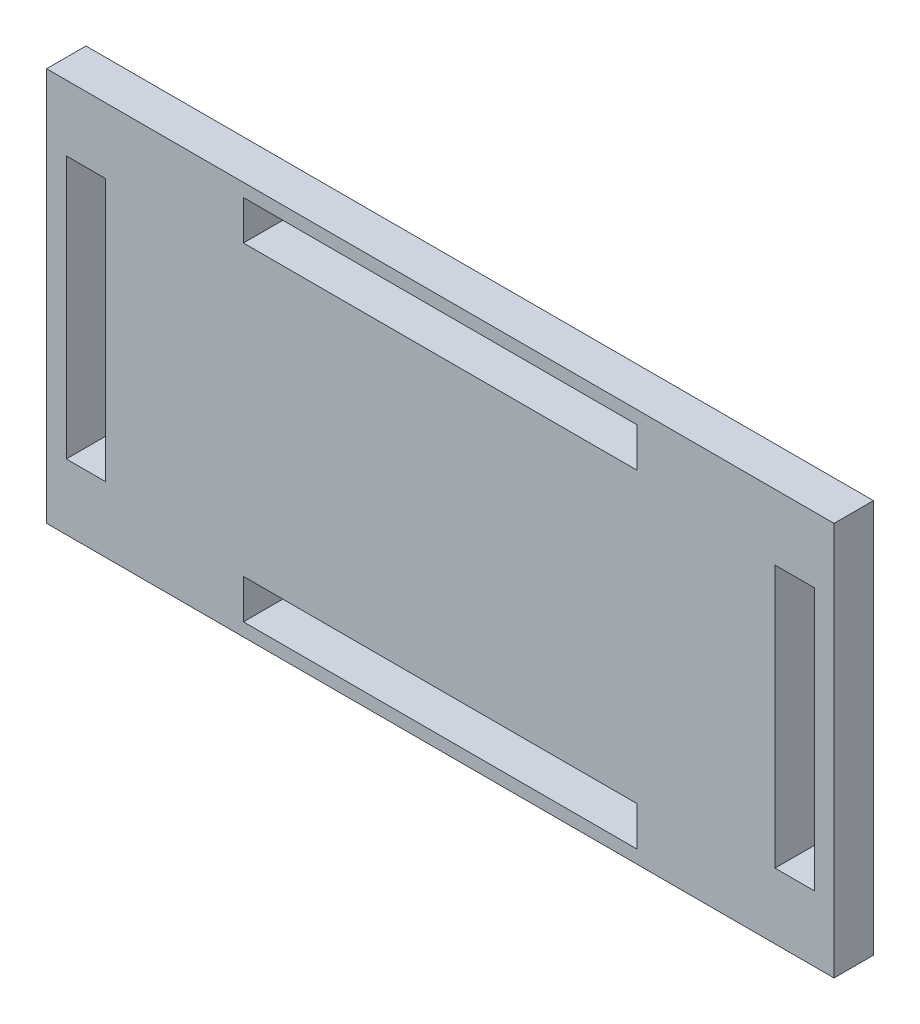
from build123d import *

# Parameters (mm, degrees)
SKETCH1_W           = 60
SKETCH1_H           = 30
SKETCH1_W_2         = 3
SKETCH1_H_2         = 20
SKETCH1_W_3         = 30
SKETCH1_H_3         = 3
BOSS_EXTRUDE1_DEPTH = 1.5


with BuildPart() as part:
    # Sketch1 → Boss-Extrude1 (new body, symmetric)
    with BuildSketch(Plane.XY):
        Rectangle(SKETCH1_W, SKETCH1_H)
        with Locations((-27, 0)):
            Rectangle(SKETCH1_W_2, SKETCH1_H_2, mode=Mode.SUBTRACT)
        with Locations((27, 0)):
            Rectangle(SKETCH1_W_2, SKETCH1_H_2, mode=Mode.SUBTRACT)
        with Locations((0, 12.5)):
            Rectangle(SKETCH1_W_3, SKETCH1_H_3, mode=Mode.SUBTRACT)
        with Locations((0, -12.5)):
            Rectangle(SKETCH1_W_3, SKETCH1_H_3, mode=Mode.SUBTRACT)
    extrude(amount=BOSS_EXTRUDE1_DEPTH, both=True)


solid = part.part
